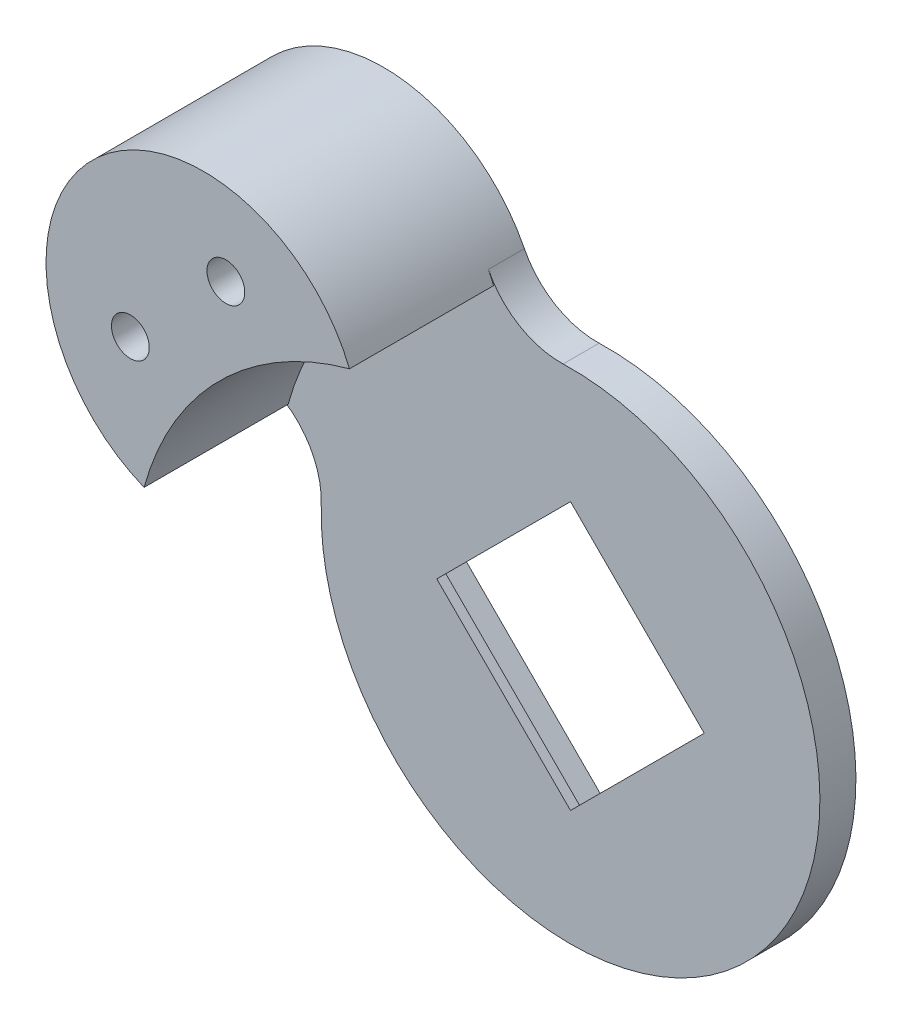
from build123d import *

# Parameters (mm, degrees)
BOSS_EXTRUDE1_DEPTH = 16
BOSS_EXTRUDE2_DEPTH = 4
SKETCH3_R           = 2.1
CUT_EXTRUDE1_DEPTH  = 21
SKETCH4_R           = 4
CUT_EXTRUDE2_DEPTH  = 14
CUT_EXTRUDE3_DEPTH  = 3
CUT_EXTRUDE4_DEPTH  = 18


with BuildPart() as part:
    # Sketch1 → Boss-Extrude1 (new body)
    with BuildSketch(Plane.XY):
        with BuildLine():
            ThreePointArc((-15.884378154, 7.150884492), (-44.46319957, 12.91724959), (-38.696834472, -15.661571826))
            ThreePointArc((-38.696834472, -15.661571826), (-30.321063947, -1.224886034), (-15.884378154, 7.150884492))
        make_face()
    extrude(amount=BOSS_EXTRUDE1_DEPTH)

    # Sketch2 → Boss-Extrude2 (add)
    with BuildSketch(Plane(origin=(0, 0, 0), x_dir=(-1, 0, 0), z_dir=(0, 0, -1))):
        with BuildLine():
            ThreePointArc((8.160247818, 3.478149899), (-12.244043633, -43.789993613), (35.024099879, -23.385702162))
            ThreePointArc((35.024099879, -23.385702162), (36.287266145, -18.514575936), (39.968005835, -15.08301433))
            ThreePointArc((39.968005835, -15.08301433), (44.46319957, 12.91724959), (16.46293565, 8.422055855))
            ThreePointArc((16.46293565, 8.422055855), (13.031374044, 4.741316164), (8.160247818, 3.478149899))
        make_face()
    extrude(amount=BOSS_EXTRUDE2_DEPTH)

    # Sketch3 → Cut-Extrude1 (cut, through all)
    with BuildSketch(Plane(origin=(0, 0, -4), x_dir=(-1, 0, 0), z_dir=(0, 0, -1))):
        with Locations((40.220558883, -1.931992815)):
            Circle(SKETCH3_R)
        with Locations((29.613957165, 8.674608903)):
            Circle(SKETCH3_R)
    extrude(amount=-CUT_EXTRUDE1_DEPTH, mode=Mode.SUBTRACT)

    # Sketch4 → Cut-Extrude2 (cut)
    with BuildSketch(Plane(origin=(0, 0, -4), x_dir=(-1, 0, 0), z_dir=(0, 0, -1))):
        with Locations((40.220558883, -1.931992815)):
            Circle(SKETCH4_R)
        with Locations((29.613957165, 8.674608903)):
            Circle(SKETCH4_R)
    extrude(amount=-CUT_EXTRUDE2_DEPTH, mode=Mode.SUBTRACT)

    # Sketch5 → Cut-Extrude3 (cut)
    with BuildSketch(Plane(origin=(0, 0, -4), x_dir=(-1, 0, 0), z_dir=(0, 0, -1))):
        Polygon((23.603549525, -24.205856422), (7.340093558, -7.942400455), (-8.923362409, -24.205856422), (7.340093558, -40.46931239), align=None)
    extrude(amount=-CUT_EXTRUDE3_DEPTH, mode=Mode.SUBTRACT)

    # Sketch6 → Cut-Extrude4 (cut, through all)
    with BuildSketch(Plane(origin=(0, 0, -1), x_dir=(-1, 0, 0), z_dir=(0, 0, -1))):
        Polygon((7.340093558, -39.055098827), (22.189335963, -24.205856422), (7.340093558, -9.356614017), (-7.509148847, -24.205856422), align=None)
    extrude(amount=-CUT_EXTRUDE4_DEPTH, mode=Mode.SUBTRACT)


solid = part.part
